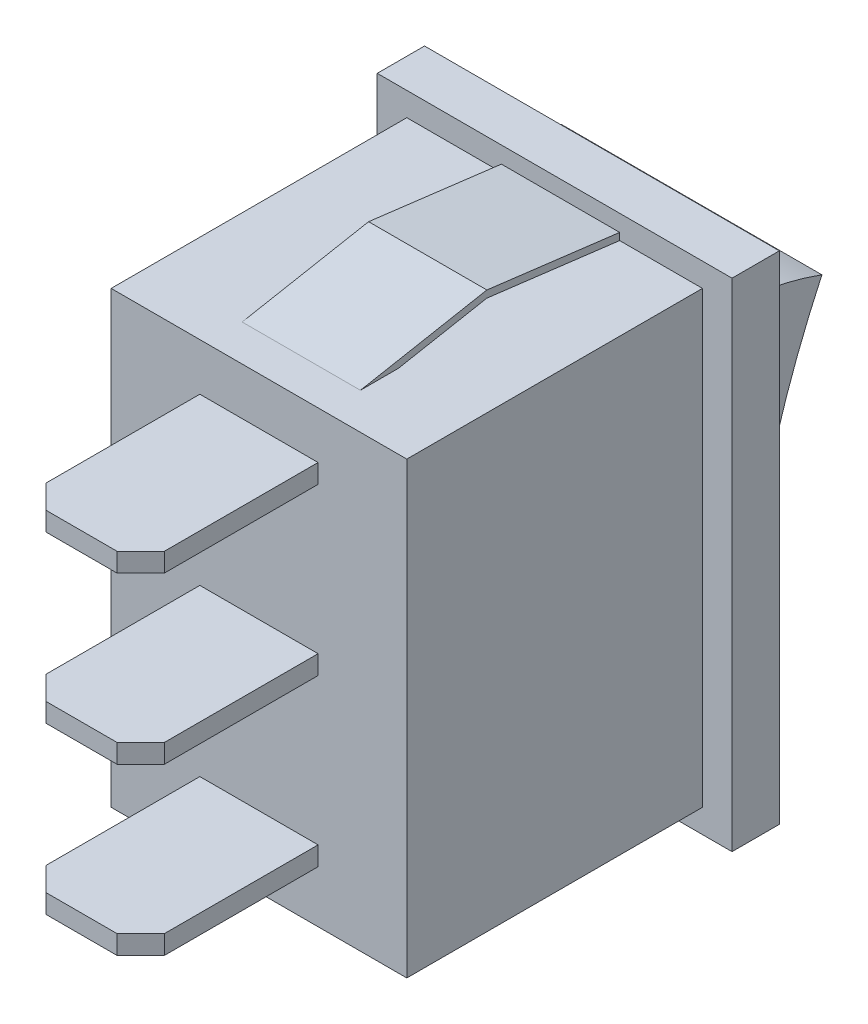
from build123d import *

# Parameters (mm, degrees)
SKETCH_1_W      = 15
SKETCH_1_H      = 21
EXTRUDE_1_DEPTH = 2
SKETCH_2_W      = 12.5
SKETCH_2_H      = 19
EXTRUDE_2_DEPTH = 12.5
SKETCH_3_W      = 5
SKETCH_3_H      = 0.8
EXTRUDE_3_DEPTH = 7.5
CHAMFER_1_SIZE  = 1
EXTRUDE_START   = -2
EXTRUDE_4_DEPTH = 11
EXTRUDE_START_2 = -3.5
EXTRUDE_5_DEPTH = 5


with BuildPart() as part:
    # Эскиз1 → Бобышка-Вытянуть1 (new body)
    with BuildSketch(Plane.XY):
        with Locations((-135.472114918, 42.369501341)):
            Rectangle(SKETCH_1_W, SKETCH_1_H)
    extrude(amount=EXTRUDE_1_DEPTH)

    # Эскиз2 → Бобышка-Вытянуть2 (add)
    with BuildSketch(Plane.XY.offset(2)):
        with Locations((-135.472114918, 42.369501341)):
            Rectangle(SKETCH_2_W, SKETCH_2_H)
    extrude(amount=EXTRUDE_2_DEPTH)

    # Эскиз3 → Бобышка-Вытянуть3 (add)
    with BuildSketch(Plane.XY.offset(14.5)):
        with Locations((-135.472114918, 49.469501341)):
            Rectangle(SKETCH_3_W, SKETCH_3_H)
        with Locations((-135.472114918, 42.469501341)):
            Rectangle(SKETCH_3_W, SKETCH_3_H)
        with Locations((-135.472114918, 35.469501341)):
            Rectangle(SKETCH_3_W, SKETCH_3_H)
    extrude(amount=EXTRUDE_3_DEPTH)

    # Фаска1
    chamfer_1_edges = [part.edges().sort_by_distance(p)[0] for p in [
        (-132.972114918, 49.469501341, 22),
        (-137.972114918, 49.469501341, 22),
        (-132.972114918, 42.469501341, 22),
        (-137.972114918, 42.469501341, 22),
        (-132.972114918, 35.469501341, 22),
        (-137.972114918, 35.469501341, 22),
    ]]
    chamfer(chamfer_1_edges, length=CHAMFER_1_SIZE)

    # Эскиз5 → Бобышка-Вытянуть4 (add)
    with BuildSketch(Plane(origin=(-127.972114918, 0, 0), x_dir=(0, 0, -1), z_dir=(1, 0, 0)).offset(EXTRUDE_START)):
        with BuildLine():
            Line((0, 49.869501341), (0, 34.869501341))
            Line((0, 34.869501341), (0.354216836, 34.869501341))
            ThreePointArc((0.354216836, 34.869501341), (1.36091461, 42.154293323), (3.8, 49.092052117))
            ThreePointArc((3.8, 49.092052117), (1.929874617, 49.626797257), (0, 49.869501341))
        make_face()
    extrude(amount=-EXTRUDE_4_DEPTH)

    # Эскиз6 → Бобышка-Вытянуть5 (add)
    with BuildSketch(Plane(origin=(-129.222114918, 0, 0), x_dir=(0, 0, -1), z_dir=(1, 0, 0)).offset(EXTRUDE_START_2)):
        Polygon((-2, 51.869501341), (-2, 52.169501341), (-7.615330186, 52.869501341), (-12.960465763, 51.869501341), (-11.35692509, 51.869501341), (-7.615330186, 52.569501341), align=None)
        Polygon((-12.960465763, 32.869501341), (-11.35692509, 32.869501341), (-7.615330186, 32.169501341), (-2, 32.869501341), (-2, 32.569501341), (-7.615330186, 31.869501341), align=None)
    extrude(amount=-EXTRUDE_5_DEPTH)


solid = part.part
